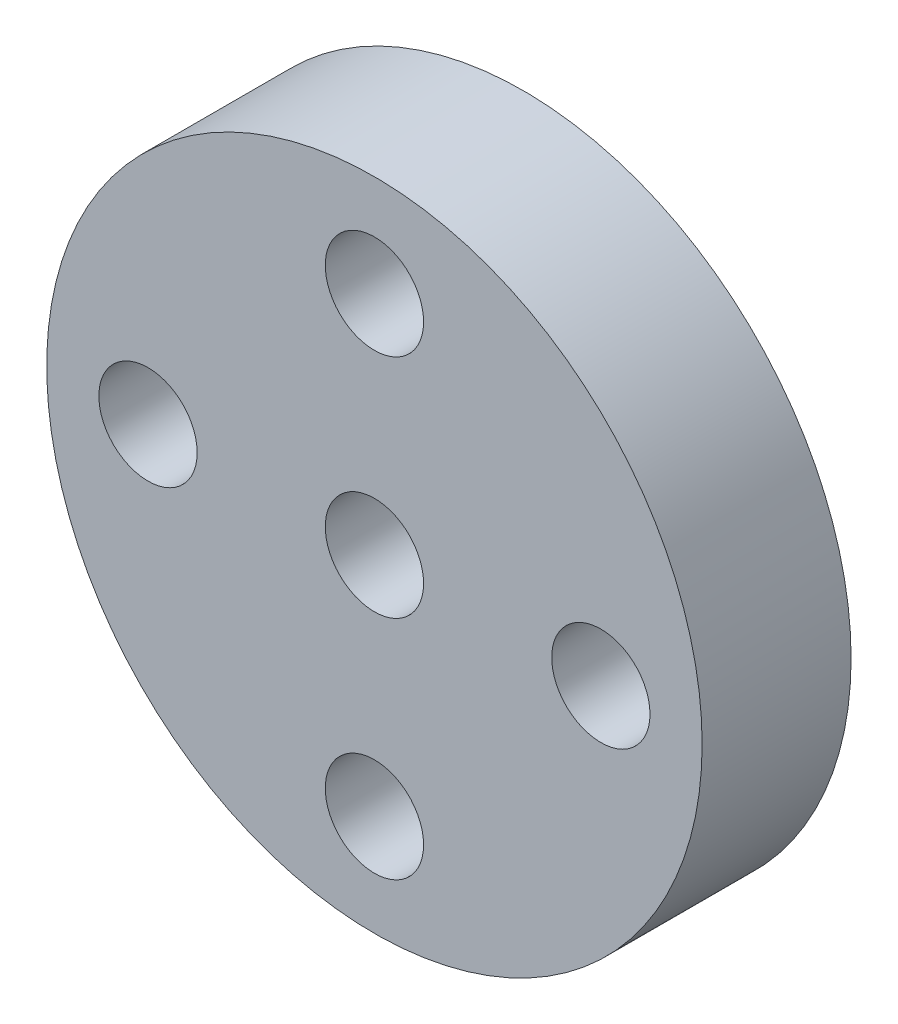
from build123d import *

# Parameters (mm, degrees)
SKETCH1_R           = 11
BOSS_EXTRUDE1_DEPTH = 5
SKETCH2_R           = 1.65
CUT_EXTRUDE2_DEPTH  = 21


with BuildPart() as part:
    # Sketch1 → Boss-Extrude1 (new body)
    with BuildSketch(Plane.XY):
        with Locations((-8.437318413, 0.250726348)):
            Circle(SKETCH1_R)
    extrude(amount=BOSS_EXTRUDE1_DEPTH)

    # Sketch2 → Cut-Extrude2 (cut)
    with BuildSketch(Plane.XY.offset(5)):
        with Locations((-8.437318413, 7.850726348)):
            Circle(SKETCH2_R)
        with Locations((-0.837318413, 0.250726348)):
            Circle(SKETCH2_R)
        with Locations((-8.437318413, -7.349273652)):
            Circle(SKETCH2_R)
        with Locations((-16.037318413, 0.250726348)):
            Circle(SKETCH2_R)
        with Locations((-8.437318413, 0.250726348)):
            Circle(SKETCH2_R)
    extrude(amount=-CUT_EXTRUDE2_DEPTH, mode=Mode.SUBTRACT)


solid = part.part
